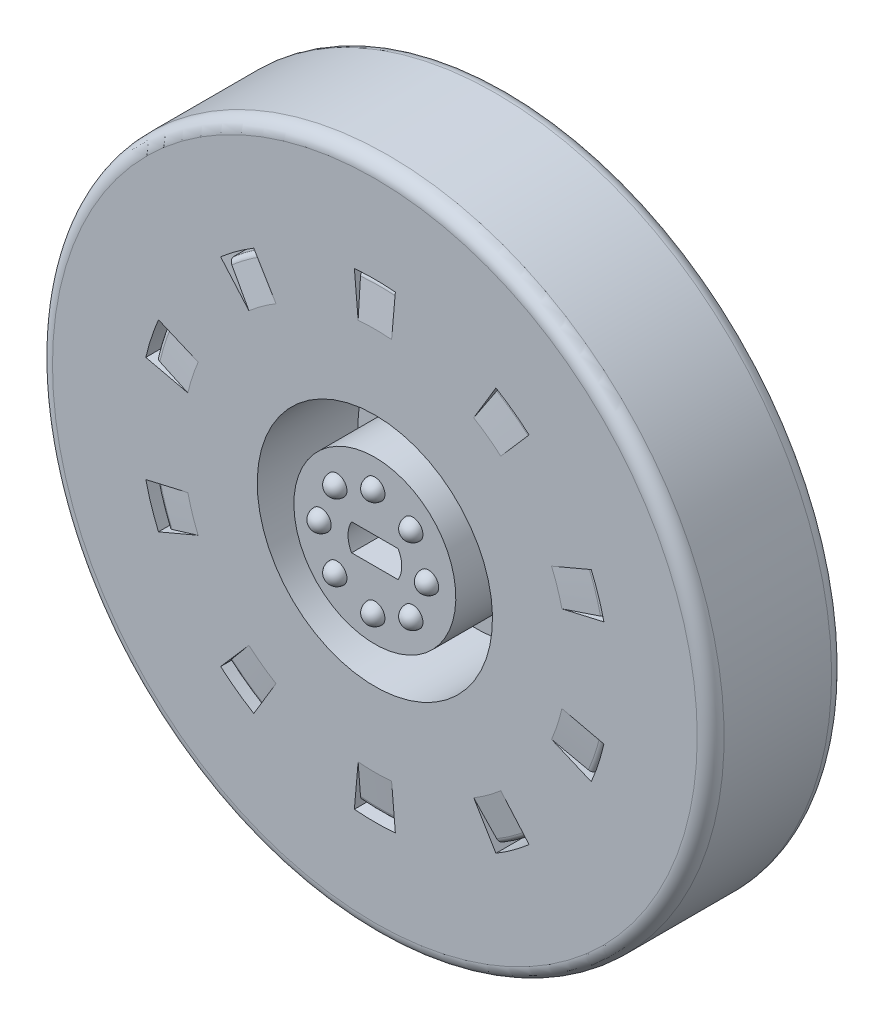
from build123d import *
from build123d.topology import SkipClean

# Parameters (mm, degrees)
FILLET2_R           = 2
CUT_EXTRUDE1_DEPTH  = 35
CUT_REVOLVE3_ANGLE  = 10
CIRPATTERN6_COUNT   = 10
SKETCH6_R           = 16.79712335
BOSS_EXTRUDE2_DEPTH = 10
CIRPATTERN5_COUNT   = 8
SKETCH9_R           = 4
CUT_EXTRUDE4_DEPTH  = 10


with BuildPart() as part:
    # Sketch1 → Revolve1 (revolve)
    with BuildSketch(Plane(origin=(0, 0, 0), x_dir=(0, 0, -1), z_dir=(1, 0, 0))):
        Polygon((0, 0), (0, 12.054712182), (15, 12.054712182), (15, 17.514385261), (0, 17.514385261), (0, 50), (20, 50), (20, 40), (4.704013112, 40), (4.704013112, 30), (20, 30), (20, 0), align=None)
    revolve(axis=Axis((0, 0, -20), (0, 0, 1)))

    # Fillet2
    fillet2_edges = [part.edges().sort_by_distance(p)[0] for p in [
        (0, -50, -20),
        (0, -50, 0),
    ]]
    fillet(fillet2_edges, radius=FILLET2_R)

    # Sketch3 → Cut-Extrude1 (cut)
    with BuildSketch(Plane.XY):
        with BuildLine():
            Line((-3.464101615, -2), (3.464101615, -2))
            ThreePointArc((3.464101615, -2), (4, 0), (3.464101615, 2))
            Line((3.464101615, 2), (-3.464101615, 2))
            ThreePointArc((-3.464101615, 2), (-4, 0), (-3.464101615, -2))
        make_face()
    extrude(amount=-CUT_EXTRUDE1_DEPTH, mode=Mode.SUBTRACT)

    # Sketch2 → Cut-Revolve3 (revolve, symmetric, cut)
    with BuildSketch(Plane(origin=(0, 0, 0), x_dir=(0, 0, -1), z_dir=(1, 0, 0))) as cut_revolve3_sk:
        with BuildLine():
            Line((0, 28.579953995), (0.797337411, 33.673838154))
            ThreePointArc((0.797337411, 33.673838154), (1.022193113, 34.115972341), (1.464458447, 34.34056998))
            Line((1.464458447, 34.34056998), (18.649598976, 34.34056998))
            ThreePointArc((18.649598976, 34.34056998), (19.049298294, 34.101727794), (19.248300485, 33.680772616))
            Line((19.248300485, 33.680772616), (20, 28.579953995))
            Line((20, 28.579953995), (20, 35))
            Line((20, 35), (0, 35))
            Line((0, 35), (0, 28.579953995))
        make_face()
    cut_revolve3 = revolve(axis=Axis((0, 0, 0), (0, 0, -1)), revolution_arc=CUT_REVOLVE3_ANGLE / 2, mode=Mode.SUBTRACT)
    cut_revolve3 = cut_revolve3 + revolve(cut_revolve3_sk.sketch, axis=Axis((0, 0, 0), (0, 0, 1)), revolution_arc=CUT_REVOLVE3_ANGLE / 2, mode=Mode.SUBTRACT)

    # CirPattern6: Cut-Revolve3 ×10 about axis
    cirpattern6_axis = Axis((0, 0, 0), (0, 0, 1))
    for i in range(1, CIRPATTERN6_COUNT):
        add(cut_revolve3.rotate(cirpattern6_axis, i * 360 / CIRPATTERN6_COUNT), mode=Mode.SUBTRACT)

    # Sketch6 → Boss-Extrude2 (add)
    with BuildSketch(Plane(origin=(0, 0, -20), x_dir=(-1, 0, 0), z_dir=(0, 0, -1))):
        with Locations(Location((0, 0, 0), (0, 0, 90))):
            Circle(SKETCH6_R)
    extrude(amount=BOSS_EXTRUDE2_DEPTH)

    # Sketch4 → Revolve4 (revolve)
    with BuildSketch(Plane.XY):
        with BuildLine():
            Line((-1.5, 8), (1.5, 8))
            ThreePointArc((1.5, 8), (0, 9.5), (-1.5, 8))
        make_face()
    revolve4 = revolve(axis=Axis((-1.5, 8, 0), (1, 0, 0)))

    # CirPattern5: Revolve4 ×8 about axis
    cirpattern5_axis = Axis((0, 0, 0), (0, 0, 1))
    for i in range(1, CIRPATTERN5_COUNT):
        add(revolve4.rotate(cirpattern5_axis, i * 360 / CIRPATTERN5_COUNT))

    # Sketch9 → Cut-Extrude4 (cut)
    with SkipClean():  # the faces are left unmerged after this step: merging them gives an invalid solid
        with BuildSketch(Plane(origin=(0, 0, -30), x_dir=(-1, 0, 0), z_dir=(0, 0, -1))):
            with Locations(Location((0, 0, 0), (0, 0, 150))):
                Circle(SKETCH9_R)
        extrude(amount=-CUT_EXTRUDE4_DEPTH, mode=Mode.SUBTRACT)


solid = part.part
